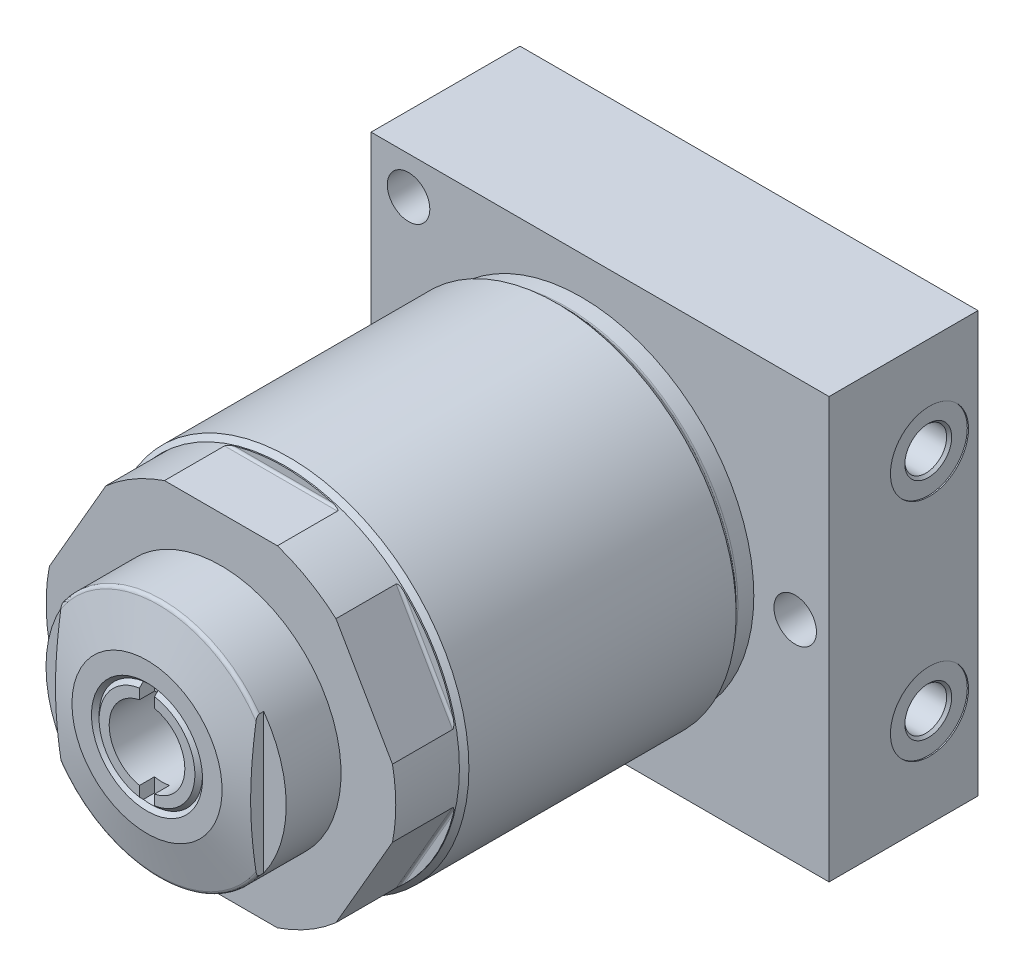
from build123d import *

# Parameters (mm, degrees)
CUT_EXTRUDE1_DEPTH      = 38.973
CIRPATTERN1_COUNT       = 6
SKETCH6_W               = 96.85
SKETCH6_H               = 31.496
EXTRUDE1_DEPTH          = 44.45
SKETCH4_R               = 8.001
CUT_EXTRUDE2_DEPTH      = 22.098
HOLE1_D                 = 8.992
HOLE1_DEPTH             = 31.496
LPATTERN1_COUNT         = 2
LPATTERN1_PITCH         = 47.626
SKETCH12_W              = 10
SKETCH12_H              = 10
CUT_EXTRUDE3_DEPTH      = 45.45
CUT_EXTRUDE3_DEPTH_BACK = 45.45
CUT_EXTRUDE4_DEPTH      = 3.175


with BuildPart() as part:
    # Sketch1 → Revolve1 (revolve)
    with BuildSketch(Plane(origin=(0, 0, 0), x_dir=(0, 0, -1), z_dir=(1, 0, 0)), mode=Mode.PRIVATE) as revolve1_sk:
        with BuildLine():
            Line((0, 0), (0, 13.9954))
            Line((0, 13.9954), (-4.6736, 13.9954))
            Line((-4.6736, 13.9954), (-4.6736, 36.487))
            Line((-4.6736, 36.487), (-24.003, 36.487))
            ThreePointArc((-24.003, 36.487), (-24.352925731, 36.556604555), (-24.649578441, 36.754821559))
            Line((-24.649578441, 36.754821559), (-25.867756881, 37.973))
            Line((-25.867756881, 37.973), (-82.3845, 37.973))
            Line((-82.3845, 37.973), (-83.388, 36.9695))
            Line((-83.388, 36.9695), (-96.85, 36.9695))
            Line((-96.85, 36.9695), (-96.85, 0))
            Line((-96.85, 0), (0, 0))
        make_face()
    revolve(revolve1_sk.sketch.rotate(Axis((0, 0, 0), (0, 0, -1)), 90), axis=Axis((0, 0, 0), (0, 0, -1)))  # turned: the seam where the file's is

    # Sketch2 → Cut-Extrude1 (cut, symmetric)
    with BuildSketch(Plane(origin=(0, 0, 0), x_dir=(0, 0, -1), z_dir=(1, 0, 0))):
        with BuildLine():
            Line((-96.85, 34.9885), (-84.15, 34.9885))
            ThreePointArc((-84.15, 34.9885), (-83.790789755, 35.137289755), (-83.642, 35.4965))
            Line((-83.642, 35.4965), (-83.642, 38.1635))
            Line((-83.642, 38.1635), (-96.85, 38.1635))
            Line((-96.85, 38.1635), (-96.85, 34.9885))
        make_face()
    cut_extrude1 = extrude(amount=CUT_EXTRUDE1_DEPTH, both=True, mode=Mode.SUBTRACT)

    # CirPattern1: Cut-Extrude1 ×6 about axis
    cirpattern1_axis = Axis((0, 0, 0), (0, 0, 1))
    for i in range(1, CIRPATTERN1_COUNT):
        add(cut_extrude1.rotate(cirpattern1_axis, i * 360 / CIRPATTERN1_COUNT), mode=Mode.SUBTRACT)

    # Sketch6 → Extrude1 (add, symmetric)
    with BuildSketch(Plane(origin=(0, 0, 0), x_dir=(1, 0, 0), z_dir=(0, 1, 0))):
        with Locations((3.975, -4.902)):
            Rectangle(SKETCH6_W, SKETCH6_H)
    extrude(amount=EXTRUDE1_DEPTH, both=True)

    # Sketch3 → Revolve2 (revolve)
    with BuildSketch(Plane(origin=(0, 0, 0), x_dir=(0, 0, -1), z_dir=(1, 0, 0)), mode=Mode.PRIVATE) as revolve2_sk:
        with BuildLine():
            Line((-112.484, 0), (-112.484, 15.875))
            Line((-112.484, 15.875), (-110.068780748, 24.818188244))
            ThreePointArc((-110.068780748, 24.818188244), (-109.787479807, 25.237840839), (-109.309, 25.4))
            Line((-109.309, 25.4), (-96.85, 25.4))
            Line((-96.85, 25.4), (-96.85, 0))
            Line((-96.85, 0), (-112.484, 0))
        make_face()
    revolve(revolve2_sk.sketch.rotate(Axis((0, 0, 0), (0, 0, 1)), 270), axis=Axis((0, 0, 0), (0, 0, 1)))  # turned: the seam where the file's is

    # Sketch4 → Cut-Extrude2 (cut)
    with BuildSketch(Plane.XY.offset(112.484)):
        Circle(SKETCH4_R)
    extrude(amount=-CUT_EXTRUDE2_DEPTH, mode=Mode.SUBTRACT)

    # Hole1
    with Locations(Plane.XY.offset(20.65)):
        with Locations((-36.5252, 36.5252), (-36.5252, -36.5252), (45.2374, 0)):
            Hole(HOLE1_D / 2, depth=HOLE1_DEPTH)

    # Sketch9 → Cut-Revolve2 (revolve, cut)
    with BuildSketch(Plane(origin=(0, -23.813, 0), x_dir=(-1, 0, 0), z_dir=(0, 1, 0)), mode=Mode.PRIVATE) as cut_revolve2_sk:
        Polygon((-52.4, 7.67), (-52.146, 7.67), (-52.146, 4.368), (-51.6126, 3.8346), (-41.5796, 3.8346), (-41.5796, -0.585), (-52.4, -0.585), align=None)
    cut_revolve2 = revolve(cut_revolve2_sk.sketch.rotate(Axis((52.4, -23.813, -0.585), (-1, 0, 0)), 180), axis=Axis((52.4, -23.813, -0.585), (-1, 0, 0)), mode=Mode.SUBTRACT)  # turned: the seam where the file's is

    # LPattern1: Cut-Revolve2 ×2
    with Locations(*[(0, i * LPATTERN1_PITCH, 0) for i in range(1, LPATTERN1_COUNT)]):
        add(cut_revolve2, mode=Mode.SUBTRACT)

    # Sketch12 → Cut-Extrude3 (cut, two sides)
    with BuildSketch(Plane(origin=(0, 0, 0), x_dir=(0, 0, -1), z_dir=(0, 1, 0))) as cut_extrude3_sk:
        with Locations((-113.445, 25.6375)):
            Rectangle(SKETCH12_W, SKETCH12_H)
        with Locations((-113.445, -25.6375)):
            Rectangle(SKETCH12_W, SKETCH12_H)
    extrude(amount=CUT_EXTRUDE3_DEPTH, mode=Mode.SUBTRACT)
    extrude(cut_extrude3_sk.sketch, amount=-CUT_EXTRUDE3_DEPTH_BACK, mode=Mode.SUBTRACT)

    # Sketch13 → Cut-Revolve4 (revolve, cut)
    with BuildSketch(Plane(origin=(0, 0, 0), x_dir=(0, 0, -1), z_dir=(1, 0, 0)), mode=Mode.PRIVATE) as cut_revolve4_sk:
        Polygon((-112.484, 11.7475), (-111.671, 10.9345), (-112.484, 10.1215), align=None)
    revolve(cut_revolve4_sk.sketch.rotate(Axis((0, 0, 0), (0, 0, 1)), 270), axis=Axis((0, 0, 0), (0, 0, 1)), mode=Mode.SUBTRACT)  # turned: the seam where the file's is

    # Sketch14 → Cut-Extrude4 (cut)
    with BuildSketch(Plane.XY.offset(112.484)):
        with BuildLine():
            Line((-1.5875, -10.818647513), (-1.5875, 10.818647513))
            ThreePointArc((-1.5875, 10.818647513), (0, 10.9345), (1.5875, 10.818647513))
            Line((1.5875, 10.818647513), (1.5875, -10.818647513))
            ThreePointArc((1.5875, -10.818647513), (0, -10.9345), (-1.5875, -10.818647513))
        make_face()
    extrude(amount=-CUT_EXTRUDE4_DEPTH, mode=Mode.SUBTRACT)


solid = part.part
